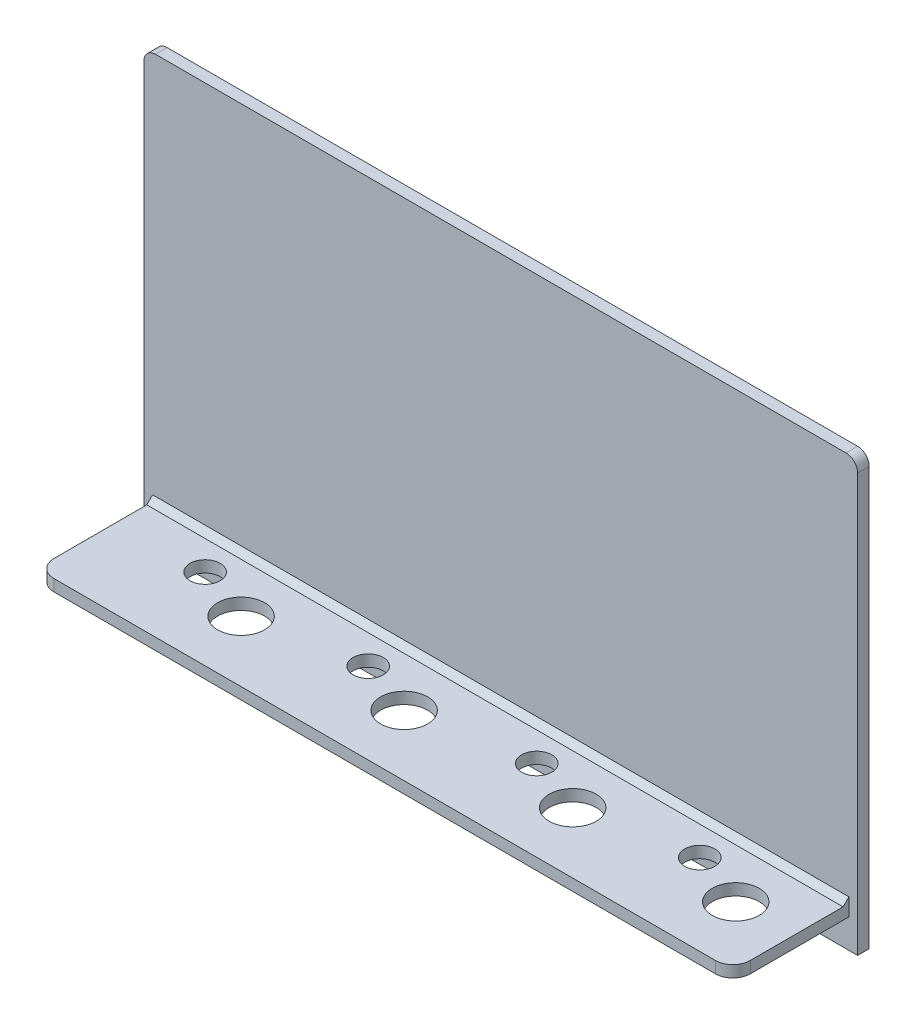
from build123d import *

# Parameters (mm, degrees)
ESQUISSE2_W                            = 123
ESQUISSE2_H                            = 74
BOSS_EXTRU_1_DEPTH                     = 2
ESQUISSE3_W                            = 120
ESQUISSE3_H                            = 2
BOSS_EXTRU_2_DEPTH                     = 20
ESQUISSE4_R                            = 4.05
ESQUISSE4_R_2                          = 2.6
ENL_V_MAT_EXTRU_1_DEPTH                = 70
R_P_TITION_LIN_AIRE1_COUNT             = 2
R_P_TITION_LIN_AIRE1_PITCH             = 28.1
R_P_TITION_LIN_AIRE2_COUNT             = 2
R_P_TITION_LIN_AIRE2_PITCH             = 57.15
R_P_TITION_LIN_AIRE2_COPY_1_SKETCH_R   = 4.05
R_P_TITION_LIN_AIRE2_COPY_1_SKETCH_R_2 = 2.6
R_P_TITION_LIN_AIRE2_COPY_1_DEPTH      = 70
CONG_1_R                               = 3
ENL_V_MAT_EXTRU_2_DEPTH                = 0.5
CONG_2_R                               = 2
CHANFREIN1_SIZE                        = 1


with BuildPart() as part:
    # Esquisse2 → Boss.-Extru.1 (new body)
    with BuildSketch(Plane.XY):
        Rectangle(ESQUISSE2_W, ESQUISSE2_H)
    extrude(amount=BOSS_EXTRU_1_DEPTH)

    # Esquisse3 → Boss.-Extru.2 (add)
    with BuildSketch(Plane.XY.offset(2)):
        with Locations((0, -31)):
            Rectangle(ESQUISSE3_W, ESQUISSE3_H)
    extrude(amount=BOSS_EXTRU_2_DEPTH)

    # Esquisse4 → Enlèv. mat.-Extru.1 (cut, through all)
    with BuildSketch(Plane.XZ.offset(32)):
        with Locations((50, 11.5)):
            Circle(ESQUISSE4_R)
        with Locations((40.3, 8)):
            Circle(ESQUISSE4_R_2)
    enl_v_mat_extru_1 = extrude(amount=-ENL_V_MAT_EXTRU_1_DEPTH, mode=Mode.SUBTRACT)

    # Répétition linéaire1: Enlèv. mat.-Extru.1 ×2
    with Locations(*[(-i * R_P_TITION_LIN_AIRE1_PITCH, 0, 0) for i in range(1, R_P_TITION_LIN_AIRE1_COUNT)]):
        add(enl_v_mat_extru_1, mode=Mode.SUBTRACT)

    # Répétition linéaire2: Enlèv. mat.-Extru.1 ×2
    with Locations(*[(-i * R_P_TITION_LIN_AIRE2_PITCH, 0, 0) for i in range(1, R_P_TITION_LIN_AIRE2_COUNT)]):
        add(enl_v_mat_extru_1, mode=Mode.SUBTRACT)

    # Répétition linéaire2 copy 1 sketch → Répétition linéaire2 copy 1 (cut, through all)
    with BuildSketch(Plane(origin=(-85.25, -32, 0), x_dir=(1, 0, 0), z_dir=(0, -1, 0))):
        with Locations((50, 11.5)):
            Circle(R_P_TITION_LIN_AIRE2_COPY_1_SKETCH_R)
        with Locations((40.3, 8)):
            Circle(R_P_TITION_LIN_AIRE2_COPY_1_SKETCH_R_2)
    extrude(amount=-R_P_TITION_LIN_AIRE2_COPY_1_DEPTH, mode=Mode.SUBTRACT)

    # Congé1
    cong_1_edges = [part.edges().sort_by_distance(p)[0] for p in [
        (-60, -31, 22),
        (60, -31, 22),
    ]]
    fillet(cong_1_edges, radius=CONG_1_R)

    # Esquisse5 → Enlèv. mat.-Extru.2 (cut)
    with BuildSketch(Plane.XZ.offset(32)):
        Polygon((-46.246474359, 19.5), (-44.026923077, 19.5), (-44.026923077, 11.5), (-45.462820513, 11.5), (-45.462820513, 18.166666667), (-47.103846154, 18.166666667), align=None)
        with BuildLine():
            Line((-18.080769231, 16.833333333), (-19.516666667, 16.833333333))
            add(Edge.make_bspline(
                [(-19.516666667, 16.833333333), (-19.510465246, 16.941951378), (-19.498348042, 17.154184515), (-19.450148867, 17.462459943), (-19.385563627, 17.753746324), (-19.299366051, 18.027024704), (-19.191053156, 18.282195785), (-19.063412113, 18.520129458), (-18.913181983, 18.739572998), (-18.743560156, 18.939468122), (-18.557426346, 19.118795883), (-18.358644872, 19.277799142), (-18.144175105, 19.40900463), (-17.917935582, 19.516974599), (-17.679964827, 19.603237587), (-17.428011263, 19.660911375), (-17.164256441, 19.699968629), (-16.983694907, 19.703386296), (-16.891666667, 19.705128205)],
                knots=[0, 0, 0, 0, 0.000326207, 0.00063739, 0.000934802, 0.001220652, 0.001495683, 0.001765295, 0.002029329, 0.002291978, 0.002550384, 0.00280367, 0.003054066, 0.003302794, 0.003554723, 0.003811658, 0.004077051, 0.00435292, 0.00435292, 0.00435292, 0.00435292], degree=3))
            add(Edge.make_bspline(
                [(-16.891666667, 19.705128205), (-16.778703308, 19.701603451), (-16.558172358, 19.694722304), (-16.237723397, 19.636023836), (-15.938459103, 19.537841578), (-15.660597015, 19.400655071), (-15.406502621, 19.226373995), (-15.176218057, 19.018572334), (-14.976707495, 18.772890302), (-14.80670598, 18.499550326), (-14.665455039, 18.21012176), (-14.566472263, 17.910840622), (-14.50141195, 17.609648618), (-14.494472865, 17.406841167), (-14.491025641, 17.306089744)],
                knots=[0, 0, 0, 0, 0.000338687, 0.000661197, 0.000973372, 0.001280835, 0.001587541, 0.001894987, 0.002208111, 0.002533585, 0.002859001, 0.003171681, 0.003477486, 0.003779381, 0.003779381, 0.003779381, 0.003779381], degree=3))
            add(Edge.make_bspline(
                [(-14.491025641, 17.306089744), (-14.492367808, 17.245148162), (-14.495069259, 17.122487811), (-14.513852803, 16.936872596), (-14.542031832, 16.747801798), (-14.584518939, 16.555437528), (-14.637503846, 16.359725863), (-14.701782196, 16.160081106), (-14.778844989, 15.957635169), (-14.867406204, 15.750109557), (-14.973059957, 15.536830517), (-15.096079067, 15.314600912), (-15.23972874, 15.083617878), (-15.402273868, 14.842577208), (-15.584503894, 14.591859063), (-15.787308406, 14.332218682), (-16.008351571, 14.062741176), (-16.165232123, 13.882610586), (-16.245833333, 13.790064103)],
                knots=[0, 0, 0, 0, 0.000182805, 0.000367941, 0.000559231, 0.000756001, 0.00095854, 0.001167341, 0.001384918, 0.001608181, 0.001843976, 0.002098627, 0.002369916, 0.002659714, 0.002970649, 0.003299545, 0.003647962, 0.00401612, 0.00401612, 0.00401612, 0.00401612], degree=3))
            Line((-16.245833333, 13.790064103), (-17.080769231, 12.833333333))
            Line((-17.080769231, 12.833333333), (-14.388461538, 12.833333333))
            Line((-14.388461538, 12.833333333), (-14.388461538, 11.5))
            Line((-14.388461538, 11.5), (-19.721794872, 11.5))
            Line((-19.721794872, 11.5), (-19.721794872, 12.227564103))
            Line((-19.721794872, 12.227564103), (-17.353205128, 14.748397436))
            add(Edge.make_bspline(
                [(-17.353205128, 14.748397436), (-17.284628368, 14.821930927), (-17.151815521, 14.964343493), (-16.962836527, 15.173491496), (-16.791827231, 15.371967959), (-16.642333649, 15.561886255), (-16.506510552, 15.737086209), (-16.39041428, 15.902848564), (-16.292982643, 16.05767477), (-16.187206782, 16.244368134), (-16.086754485, 16.467033193), (-15.994583423, 16.72355247), (-15.938398782, 16.968725821), (-15.930643525, 17.128486047), (-15.926923077, 17.205128205)],
                knots=[0, 0, 0, 0, 0.00030164, 0.000584187, 0.000845616, 0.001087386, 0.001309189, 0.001510583, 0.001694215, 0.00185781, 0.002153973, 0.002425634, 0.002674899, 0.002904742, 0.002904742, 0.002904742, 0.002904742], degree=3))
            add(Edge.make_bspline(
                [(-15.926923077, 17.205128205), (-15.929704766, 17.27927358), (-15.935094735, 17.422942131), (-15.994326125, 17.62730988), (-16.08608945, 17.812344015), (-16.215396933, 17.972515506), (-16.372028795, 18.104139041), (-16.553031624, 18.202036929), (-16.756929715, 18.258523561), (-16.899866161, 18.26559367), (-16.973397436, 18.269230769)],
                knots=[0, 0, 0, 0, 0.000221855, 0.00042988, 0.000632704, 0.000837933, 0.00104271, 0.001242748, 0.001450773, 0.001671165, 0.001671165, 0.001671165, 0.001671165], degree=3))
            add(Edge.make_bspline(
                [(-16.973397436, 18.269230769), (-17.011384629, 18.267887181), (-17.086168519, 18.265242112), (-17.196094992, 18.247634603), (-17.300697929, 18.216603207), (-17.401141618, 18.175025504), (-17.496354098, 18.11991396), (-17.586095214, 18.051980202), (-17.6713105, 17.972950581), (-17.751609126, 17.883072211), (-17.824691359, 17.782767925), (-17.88960273, 17.672953795), (-17.943273628, 17.553697988), (-17.990527438, 17.426574862), (-18.026971837, 17.290219011), (-18.05350788, 17.145446509), (-18.073681462, 16.992492883), (-18.078363662, 16.887351648), (-18.080769231, 16.833333333)],
                knots=[0, 0, 0, 0, 0.000113962, 0.000224353, 0.000332879, 0.000440621, 0.000549748, 0.000661928, 0.000777602, 0.000897911, 0.001022922, 0.001149352, 0.00127986, 0.001414723, 0.00155584, 0.001702621, 0.001856074, 0.002018219, 0.002018219, 0.002018219, 0.002018219], degree=3))
        make_face()
        with BuildLine():
            Line((11.276923077, 17.551282051), (9.841025641, 17.551282051))
            add(Edge.make_bspline(
                [(9.841025641, 17.551282051), (9.851163623, 17.623057442), (9.871038465, 17.76376834), (9.918596304, 17.967482668), (9.975480612, 18.160719649), (10.046497764, 18.342867342), (10.129789329, 18.514250213), (10.224508327, 18.675456363), (10.331678703, 18.825793865), (10.413825932, 18.916357773), (10.454807692, 18.961538462)],
                knots=[0, 0, 0, 0, 0.000217365, 0.000426129, 0.000626904, 0.000821238, 0.001011889, 0.001197959, 0.001381647, 0.001564515, 0.001564515, 0.001564515, 0.001564515], degree=3))
            add(Edge.make_bspline(
                [(10.454807692, 18.961538462), (10.513918451, 19.021151106), (10.630419544, 19.138641364), (10.825106534, 19.289133406), (11.029174453, 19.419374034), (11.246715975, 19.522629745), (11.474345987, 19.606203282), (11.713874683, 19.662339816), (11.964323262, 19.699586901), (12.135222911, 19.703255869), (12.222435897, 19.705128205)],
                knots=[0, 0, 0, 0, 0.000251608, 0.000495892, 0.000736432, 0.000976549, 0.001216838, 0.00146249, 0.001713377, 0.001974836, 0.001974836, 0.001974836, 0.001974836], degree=3))
            add(Edge.make_bspline(
                [(12.222435897, 19.705128205), (12.29997273, 19.703297712), (12.452394518, 19.699699333), (12.676416195, 19.670813493), (12.890002117, 19.620150946), (13.095409948, 19.553910803), (13.289618809, 19.463780018), (13.476915079, 19.359157361), (13.652065692, 19.230833324), (13.815480467, 19.085840076), (13.965608105, 18.929015684), (14.095619298, 18.761383307), (14.207392253, 18.58742079), (14.299478384, 18.405682836), (14.370280105, 18.21586192), (14.4194186, 18.019054614), (14.451580937, 17.815695187), (14.454785146, 17.677474524), (14.456410256, 17.607371795)],
                knots=[0, 0, 0, 0, 0.000232571, 0.000457187, 0.000676041, 0.000890408, 0.00110341, 0.001317291, 0.001533025, 0.001753283, 0.001972061, 0.002183314, 0.002388698, 0.002591522, 0.002793344, 0.00299507, 0.003199275, 0.003409431, 0.003409431, 0.003409431, 0.003409431], degree=3))
            add(Edge.make_bspline(
                [(14.456410256, 17.607371795), (14.453075433, 17.520555403), (14.446510192, 17.349640619), (14.392637631, 17.099494133), (14.308312424, 16.860309453), (14.18649646, 16.635433131), (14.034195479, 16.425477154), (13.847327277, 16.237460981), (13.631214344, 16.068436774), (13.468975487, 15.977603144), (13.385897436, 15.931089744)],
                knots=[0, 0, 0, 0, 0.000260213, 0.00051228, 0.000764209, 0.001018734, 0.001276767, 0.001539675, 0.001811507, 0.002096791, 0.002096791, 0.002096791, 0.002096791], degree=3))
            add(Edge.make_bspline(
                [(13.385897436, 15.931089744), (13.442920936, 15.912367728), (13.554969556, 15.875579807), (13.714233196, 15.803126413), (13.865674719, 15.723946862), (14.006686357, 15.631961097), (14.13867064, 15.530888614), (14.260822977, 15.419865408), (14.3738732, 15.299133563), (14.475975809, 15.168029098), (14.566595864, 15.028648775), (14.647904414, 14.884212196), (14.714825883, 14.732528955), (14.771516698, 14.575331376), (14.814677858, 14.411206651), (14.845067171, 14.240790749), (14.862632939, 14.0644724), (14.865312019, 13.945016825), (14.866666667, 13.884615385)],
                knots=[0, 0, 0, 0, 0.000179923, 0.000353541, 0.000524167, 0.000692192, 0.000857908, 0.001022411, 0.00118682, 0.001353518, 0.0015202, 0.001685194, 0.001850188, 0.002016955, 0.002186046, 0.002358625, 0.002535787, 0.00271699, 0.00271699, 0.00271699, 0.00271699], degree=3))
            add(Edge.make_bspline(
                [(14.866666667, 13.884615385), (14.863920613, 13.79584979), (14.858505955, 13.620822117), (14.824082093, 13.363024266), (14.759991064, 13.117236919), (14.675675765, 12.880631922), (14.563208307, 12.656263759), (14.430853017, 12.438983487), (14.268161773, 12.236326327), (14.08735839, 12.042934547), (13.886565692, 11.8671114), (13.668873742, 11.714680644), (13.4390694, 11.583867934), (13.195698757, 11.47767045), (12.938846367, 11.395886241), (12.66908473, 11.336768844), (12.385280384, 11.300599843), (12.191561712, 11.296808209), (12.092628205, 11.294871795)],
                knots=[0, 0, 0, 0, 0.000266334, 0.000525157, 0.00077819, 0.001027104, 0.001277232, 0.001529833, 0.001788879, 0.002055295, 0.002323341, 0.002587885, 0.002851262, 0.003115355, 0.003382949, 0.003658632, 0.003942878, 0.004239565, 0.004239565, 0.004239565, 0.004239565], degree=3))
            add(Edge.make_bspline(
                [(12.092628205, 11.294871795), (11.999038703, 11.296913417), (11.816036816, 11.300905538), (11.548358257, 11.335459369), (11.293955123, 11.391197503), (11.052178175, 11.469765025), (10.823962828, 11.571653674), (10.607239536, 11.692980193), (10.406332965, 11.840742415), (10.21900462, 12.008270072), (10.049410009, 12.196226592), (9.897832365, 12.400258054), (9.767614003, 12.621140307), (9.658220894, 12.85792965), (9.570508246, 13.111041482), (9.501320766, 13.379961087), (9.452992179, 13.665213852), (9.438273607, 13.861473822), (9.430769231, 13.961538462)],
                knots=[0, 0, 0, 0, 0.000280673, 0.000548819, 0.000808162, 0.001061048, 0.001310003, 0.001556881, 0.001804662, 0.002056596, 0.002309604, 0.002562814, 0.002817868, 0.003077429, 0.003344024, 0.003620381, 0.003909661, 0.004210576, 0.004210576, 0.004210576, 0.004210576], degree=3))
            Line((9.430769231, 13.961538462), (10.866666667, 13.961538462))
            add(Edge.make_bspline(
                [(10.866666667, 13.961538462), (10.875765799, 13.911224647), (10.893488745, 13.8132253), (10.928056265, 13.67134403), (10.973102567, 13.540378855), (11.025187298, 13.41916576), (11.08144665, 13.306113258), (11.1494214, 13.205396659), (11.224130717, 13.114281094), (11.331936805, 13.005961905), (11.486053034, 12.894668461), (11.694161, 12.797949164), (11.925661405, 12.741259773), (12.087503276, 12.734343841), (12.171153846, 12.730769231)],
                knots=[0, 0, 0, 0, 0.000153378, 0.000298744, 0.000437604, 0.000568279, 0.000694425, 0.000815765, 0.000931904, 0.001047489, 0.001273473, 0.00149789, 0.001732264, 0.001983003, 0.001983003, 0.001983003, 0.001983003], degree=3))
            add(Edge.make_bspline(
                [(12.171153846, 12.730769231), (12.215541795, 12.73153041), (12.302487858, 12.733021391), (12.430198677, 12.749546914), (12.551861213, 12.776764463), (12.667702071, 12.813752103), (12.7784587, 12.860118422), (12.882014982, 12.919905016), (12.980481656, 12.989415467), (13.072788297, 13.067563666), (13.158081536, 13.152717228), (13.229050527, 13.247010332), (13.293911049, 13.342828978), (13.341882358, 13.446441961), (13.38391556, 13.552273794), (13.409642027, 13.664165843), (13.429067357, 13.779770912), (13.430196279, 13.858885946), (13.430769231, 13.899038462)],
                knots=[0, 0, 0, 0, 0.0001331, 0.000260712, 0.000385517, 0.000506646, 0.000625117, 0.000744977, 0.00086458, 0.000986259, 0.001107515, 0.001225159, 0.001339841, 0.001453803, 0.001566906, 0.00168079, 0.001797513, 0.001917801, 0.001917801, 0.001917801, 0.001917801], degree=3))
            add(Edge.make_bspline(
                [(13.430769231, 13.899038462), (13.429248152, 13.942952078), (13.426220033, 14.030374026), (13.401479984, 14.157947977), (13.362410217, 14.280663835), (13.308137539, 14.397978159), (13.235662426, 14.509458549), (13.1501426, 14.617341641), (13.044840515, 14.716012311), (12.929310026, 14.813545279), (12.795340044, 14.89856461), (12.649455096, 14.977024962), (12.487821099, 15.039455179), (12.314383683, 15.095216926), (12.125862118, 15.13594444), (11.923427052, 15.165516584), (11.707405044, 15.187528463), (11.558498266, 15.19068643), (11.482051282, 15.192307692)],
                knots=[0, 0, 0, 0, 0.000131654, 0.000262094, 0.00038829, 0.000517343, 0.00064849, 0.000786394, 0.000929193, 0.001080625, 0.001239311, 0.001404188, 0.00157679, 0.001758241, 0.001950315, 0.002154521, 0.002371867, 0.002601174, 0.002601174, 0.002601174, 0.002601174], degree=3))
            Line((11.482051282, 15.192307692), (11.482051282, 16.525641026))
            add(Edge.make_bspline(
                [(11.482051282, 16.525641026), (11.577232323, 16.533746948), (11.755297202, 16.548911522), (12.002460802, 16.584374408), (12.210540692, 16.631776393), (12.384538076, 16.688964322), (12.529014356, 16.762408523), (12.655228035, 16.843487676), (12.763929227, 16.937649265), (12.855796315, 17.042085401), (12.929287127, 17.154240018), (12.981299643, 17.272369901), (13.015645991, 17.392819965), (13.018900305, 17.475204178), (13.020512821, 17.516025641)],
                knots=[0, 0, 0, 0, 0.000286554, 0.000536087, 0.000748334, 0.000926219, 0.00108389, 0.001233238, 0.001375253, 0.001513798, 0.001649374, 0.001775641, 0.001900034, 0.002022208, 0.002022208, 0.002022208, 0.002022208], degree=3))
            add(Edge.make_bspline(
                [(13.020512821, 17.516025641), (13.017730769, 17.568109395), (13.012300794, 17.669765856), (12.970128663, 17.815257667), (12.896922622, 17.944951557), (12.798766176, 18.058574615), (12.679159134, 18.153481108), (12.538958712, 18.222381604), (12.38120727, 18.262863722), (12.27022063, 18.267060354), (12.212820513, 18.269230769)],
                knots=[0, 0, 0, 0, 0.000156116, 0.000304706, 0.000449621, 0.00059963, 0.000752555, 0.000904495, 0.001065023, 0.001236976, 0.001236976, 0.001236976, 0.001236976], degree=3))
            add(Edge.make_bspline(
                [(12.212820513, 18.269230769), (12.16079376, 18.266669907), (12.057556748, 18.261588372), (11.906593337, 18.22366114), (11.763228391, 18.159815365), (11.630430596, 18.071775804), (11.510116913, 17.966044023), (11.411374091, 17.840826675), (11.329244494, 17.703625748), (11.294431921, 17.60226236), (11.276923077, 17.551282051)],
                knots=[0, 0, 0, 0, 0.000155977, 0.000309505, 0.00046376, 0.000624664, 0.000785831, 0.000942005, 0.001101426, 0.001262737, 0.001262737, 0.001262737, 0.001262737], degree=3))
        make_face()
        Polygon((40.751923077, 19.705128205), (42.248717949, 19.705128205), (42.248717949, 14.474358974), (42.966666667, 14.474358974), (42.966666667, 13.141025641), (42.248717949, 13.141025641), (42.248717949, 11.5), (40.812820513, 11.5), (40.812820513, 13.141025641), (37.428205128, 13.141025641), (37.428205128, 14.594551282), align=None)
        Polygon((40.812820513, 14.474358974), (40.812820513, 17.197115385), (39.041987179, 14.474358974), align=None, mode=Mode.SUBTRACT)
    extrude(amount=-ENL_V_MAT_EXTRU_2_DEPTH, mode=Mode.SUBTRACT)

    # Congé2
    cong_2_edges = [part.edges().sort_by_distance(p)[0] for p in [
        (-61.5, 37, 1),
        (61.5, 37, 1),
    ]]
    fillet(cong_2_edges, radius=CONG_2_R)

    # Chanfrein1
    chanfrein1_edges = [part.edges().sort_by_distance(p)[0] for p in [
        (0, -30, 2),
    ]]
    chamfer(chanfrein1_edges, length=CHANFREIN1_SIZE)


solid = part.part
